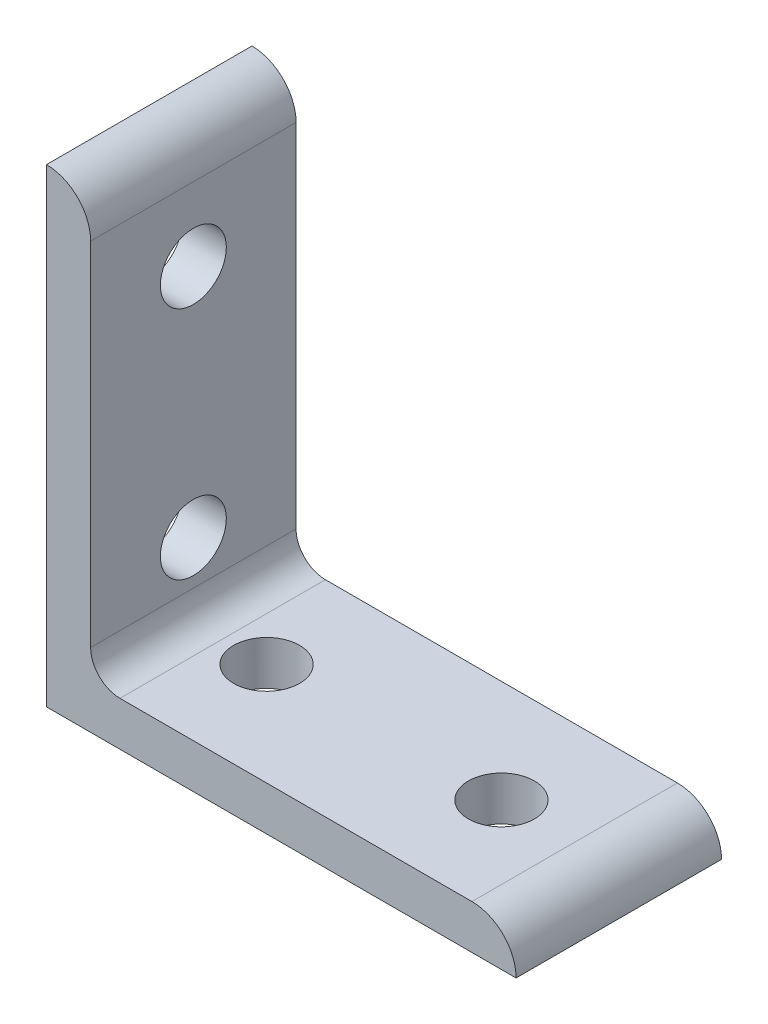
from build123d import *

# Parameters (mm, degrees)
BOSS_EXTRUDE1_DEPTH = 11.1125
SKETCH2_R           = 3.5687
CUT_EXTRUDE1_DEPTH  = 51.8
SKETCH3_R           = 3.5687
CUT_EXTRUDE2_DEPTH  = 51.8


with BuildPart() as part:
    # Sketch1 → Boss-Extrude1 (new body, symmetric)
    with BuildSketch(Plane.XY):
        with BuildLine():
            Line((0, 0), (0, 50.8))
            ThreePointArc((0, 50.8), (3.376576302, 49.401376302), (4.7752, 46.0248))
            Line((4.7752, 46.0248), (4.7752, 7.9502))
            ThreePointArc((4.7752, 7.9502), (5.70513597, 5.70513597), (7.9502, 4.7752))
            Line((7.9502, 4.7752), (46.0248, 4.7752))
            ThreePointArc((46.0248, 4.7752), (49.401376302, 3.376576302), (50.8, 0))
            Line((50.8, 0), (0, 0))
        make_face()
    extrude(amount=BOSS_EXTRUDE1_DEPTH, both=True)

    # Sketch2 → Cut-Extrude1 (cut, through all)
    with BuildSketch(Plane(origin=(0, 0, 0), x_dir=(1, 0, 0), z_dir=(0, 1, 0))):
        with Locations((12.7, 0)):
            Circle(SKETCH2_R)
        with Locations((38.1, 0)):
            Circle(SKETCH2_R)
    extrude(amount=CUT_EXTRUDE1_DEPTH, mode=Mode.SUBTRACT)

    # Sketch3 → Cut-Extrude2 (cut, through all)
    with BuildSketch(Plane(origin=(0, 0, 0), x_dir=(0, 0, -1), z_dir=(1, 0, 0))):
        with Locations((0, 12.7)):
            Circle(SKETCH3_R)
        with Locations((0, 38.1)):
            Circle(SKETCH3_R)
    extrude(amount=CUT_EXTRUDE2_DEPTH, mode=Mode.SUBTRACT)


solid = part.part
